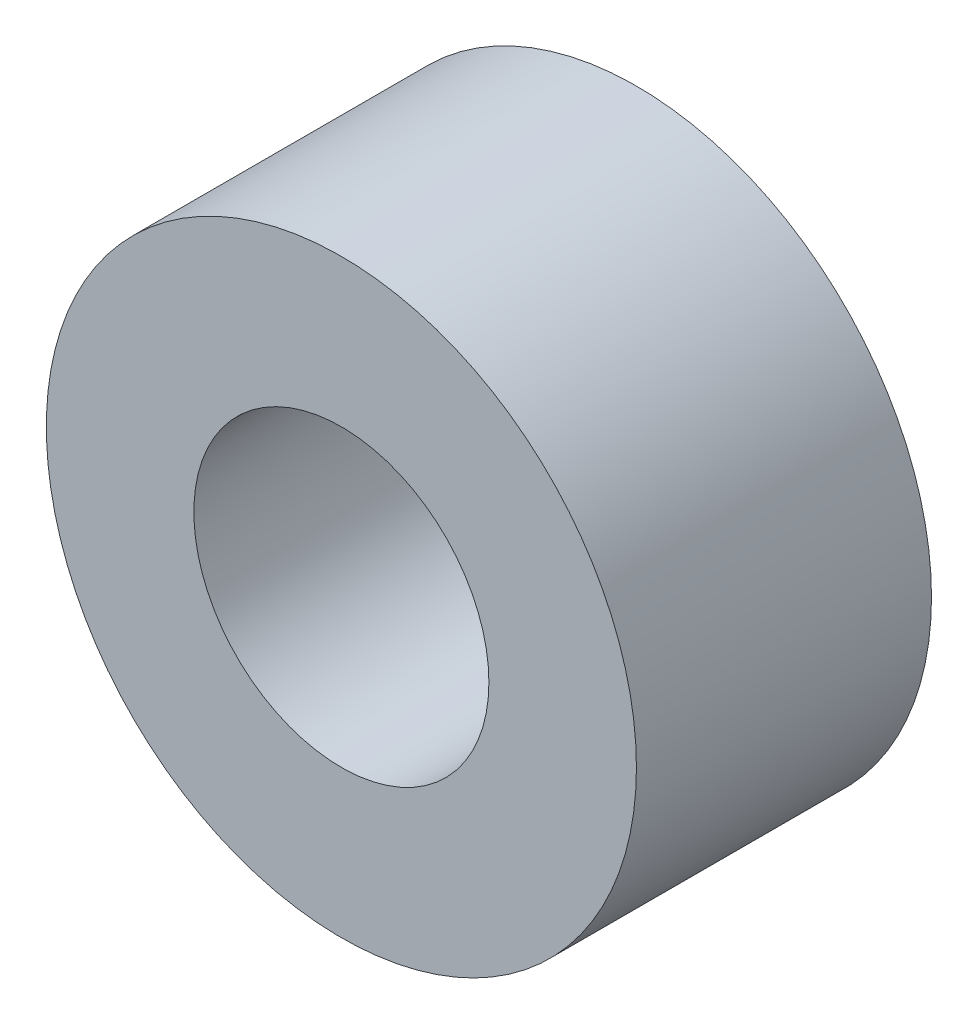
from build123d import *

# Parameters (mm, degrees)
SKETCH_1_R      = 3
SKETCH_1_R_2    = 1.5
EXTRUDE_1_DEPTH = 3


with BuildPart() as part:
    # 草图1 → 凸台-拉伸1 (new body)
    with BuildSketch(Plane.XY):
        Circle(SKETCH_1_R)
        Circle(SKETCH_1_R_2, mode=Mode.SUBTRACT)
    extrude(amount=EXTRUDE_1_DEPTH)


solid = part.part
